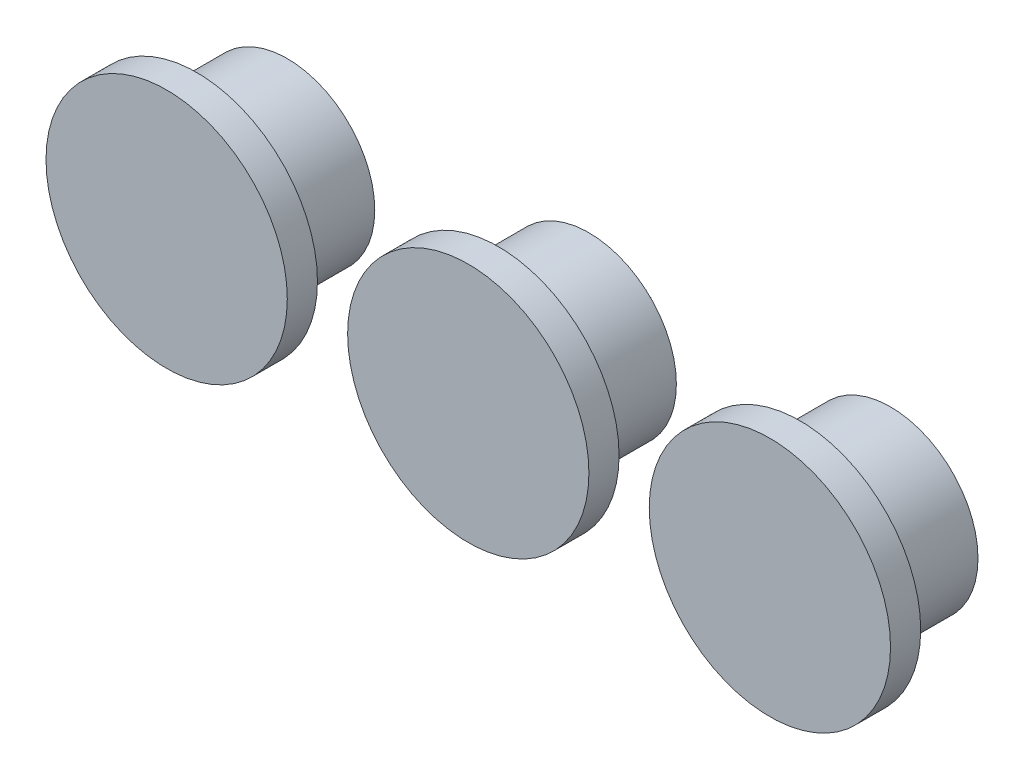
from build123d import *

# Parameters (mm, degrees)
ESQUISSE1_R                = 2.9
BOSS_EXTRU_1_DEPTH         = 3
ESQUISSE2_R                = 4
BOSS_EXTRU_2_DEPTH         = 1
R_P_TITION_LIN_AIRE2_COUNT = 3
R_P_TITION_LIN_AIRE2_PITCH = 10
ESQUISSE4_W                = 3
ESQUISSE4_H                = 3
ESQUISSE4_W_2              = 2.253615753
ESQUISSE4_H_2              = 0.614622478
BOSS_EXTRU_3_DEPTH         = 0.5


with BuildPart() as part:
    # Esquisse1 → Boss.-Extru.1 (new body)
    with BuildSketch(Plane.XY):
        Circle(ESQUISSE1_R)
    extrude(amount=BOSS_EXTRU_1_DEPTH)

    # Esquisse2 → Boss.-Extru.2 (add)
    with BuildSketch(Plane.XY.offset(3)):
        Circle(ESQUISSE2_R)
    extrude(amount=BOSS_EXTRU_2_DEPTH)


with BuildPart() as r_p_tition_lin_aire2_1:
    # Répétition linéaire2: pattern copy
    add(part.part.moved(Location(Vector(-1, 0, 0) * (1 * R_P_TITION_LIN_AIRE2_PITCH))))


with BuildPart() as r_p_tition_lin_aire2_2:
    # Répétition linéaire2: pattern copy
    add(part.part.moved(Location(Vector(-1, 0, 0) * (2 * R_P_TITION_LIN_AIRE2_PITCH))))


with BuildPart() as part_1:
    add(part.part)

    add(r_p_tition_lin_aire2_1.part)  # Boss.-Extru.3 merges Répétition linéaire2_1

    add(r_p_tition_lin_aire2_2.part)  # Boss.-Extru.3 merges Répétition linéaire2_2
    # Esquisse4 → Boss.-Extru.3 (add)
    with BuildSketch(Plane(origin=(0, 0, 0), x_dir=(-1, 0, 0), z_dir=(0, 0, -1))):
        with Locations((9.942046118, 0.058344616)):
            Rectangle(ESQUISSE4_W, ESQUISSE4_H)
        Polygon((2.342989472, -0.357020155), (0.362539264, -0.357020155), (0.362539264, -2.337470363), (-0.252083214, -2.337470363), (-0.252083214, -0.357020155), (-2.232533422, -0.357020155), (-2.232533422, 0.189310936), (-0.252083214, 0.189310936), (-0.252083214, 2.169761144), (0.362539264, 2.169761144), (0.362539264, 0.189310936), (2.342989472, 0.189310936), align=None)
        with Locations((19.973138969, 0.056052833)):
            Rectangle(ESQUISSE4_W_2, ESQUISSE4_H_2)
    extrude(amount=BOSS_EXTRU_3_DEPTH)


solid = part_1.part
